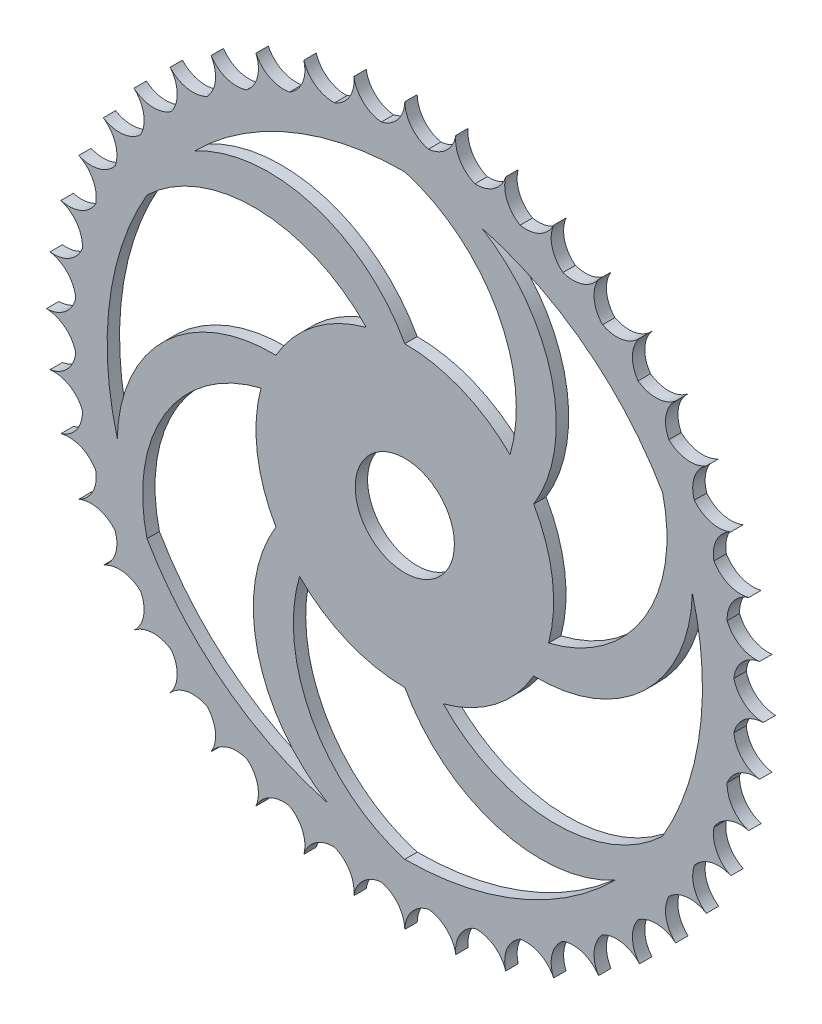
from build123d import *

# Parameters (mm, degrees)
SALIENTE_EXTRUIR1_DEPTH = 1.5875
CROQUIS3_R              = 12.7
CORTAR_EXTRUIR1_DEPTH   = 130.790821914


with BuildPart() as part:
    # Croquis2 → Saliente-Extruir1 (new, symmetric)
    with BuildSketch(Plane.XY):
        with BuildLine():
            ThreePointArc((84.239816471, -6.024948705), (86.969836616, -1.73589321), (91.748505392, 1.878e-06))
            ThreePointArc((91.748505392, 1.878e-06), (86.969836616, 1.735896967), (84.239816471, 6.024952462))
            ThreePointArc((84.239816471, 6.024952462), (86.331652708, 10.658873931), (90.814637898, 13.057175585))
            ThreePointArc((90.814637898, 13.057175585), (85.837565451, 14.095326291), (82.524936735, 17.952203009))
            ThreePointArc((82.524936735, 17.952203009), (83.936005311, 22.836657176), (88.032046263, 25.848542889))
            ThreePointArc((88.032046263, 25.848542889), (82.957888988, 26.167815457), (79.130087269, 29.513998512))
            ThreePointArc((79.130087269, 29.513998512), (79.831662898, 34.549551974), (83.457376031, 38.113708439))
            ThreePointArc((83.457376031, 38.113708439), (78.389429136, 37.7076034), (74.124377419, 40.474974154))
            ThreePointArc((74.124377419, 40.474974154), (74.102178043, 45.559117564), (77.183754293, 49.602988834))
            ThreePointArc((77.183754293, 49.602988834), (72.225186563, 48.479773316), (67.609709002, 50.611996081))
            ThreePointArc((67.609709002, 50.611996081), (66.864186536, 55.641230941), (69.338893898, 60.082495458))
            ThreePointArc((69.338893898, 60.082495458), (64.590647472, 58.26503489), (59.71870188, 59.718703759))
            ThreePointArc((59.71870188, 59.718703759), (58.265033012, 64.590649351), (60.082493579, 69.338895776))
            ThreePointArc((60.082493579, 69.338895776), (55.641229063, 66.864188414), (50.611994202, 67.609710881))
            ThreePointArc((50.611994202, 67.609710881), (48.479771438, 72.225188442), (49.602986956, 77.183756171))
            ThreePointArc((49.602986956, 77.183756171), (45.559115686, 74.102179921), (40.474972276, 74.124379298))
            ThreePointArc((40.474972276, 74.124379298), (37.707601522, 78.389431014), (38.11370656, 83.457377909))
            ThreePointArc((38.11370656, 83.457377909), (34.549550095, 79.831664776), (29.513996633, 79.130089148))
            ThreePointArc((29.513996633, 79.130089148), (26.167813579, 82.957890866), (25.84854101, 88.032048142))
            ThreePointArc((25.84854101, 88.032048142), (22.836655297, 83.93600719), (17.952201131, 82.524938613))
            ThreePointArc((17.952201131, 82.524938613), (14.095324412, 85.837567329), (13.057173707, 90.814639776))
            ThreePointArc((13.057173707, 90.814639776), (10.658872053, 86.331654587), (6.024950583, 84.239818349))
            ThreePointArc((6.024950583, 84.239818349), (1.735895089, 86.969838494), (0, 91.74850727))
            ThreePointArc((0, 91.74850727), (-1.735895089, 86.969838494), (-6.024950583, 84.239818349))
            ThreePointArc((-6.024950583, 84.239818349), (-10.658872053, 86.331654587), (-13.057173707, 90.814639776))
            ThreePointArc((-13.057173707, 90.814639776), (-14.095324412, 85.837567329), (-17.952201131, 82.524938613))
            ThreePointArc((-17.952201131, 82.524938613), (-22.836655297, 83.93600719), (-25.84854101, 88.032048142))
            ThreePointArc((-25.84854101, 88.032048142), (-26.167813579, 82.957890866), (-29.513996633, 79.130089148))
            ThreePointArc((-29.513996633, 79.130089148), (-34.549550095, 79.831664776), (-38.11370656, 83.457377909))
            ThreePointArc((-38.11370656, 83.457377909), (-37.707601522, 78.389431014), (-40.474972276, 74.124379298))
            ThreePointArc((-40.474972276, 74.124379298), (-45.559115686, 74.102179921), (-49.602986956, 77.183756171))
            ThreePointArc((-49.602986956, 77.183756171), (-48.479771438, 72.225188442), (-50.611994202, 67.609710881))
            ThreePointArc((-50.611994202, 67.609710881), (-55.641229063, 66.864188414), (-60.082493579, 69.338895776))
            ThreePointArc((-60.082493579, 69.338895776), (-58.265033012, 64.590649351), (-59.71870188, 59.718703759))
            ThreePointArc((-59.71870188, 59.718703759), (-64.590647472, 58.26503489), (-69.338893898, 60.082495458))
            ThreePointArc((-69.338893898, 60.082495458), (-66.864186536, 55.641230941), (-67.609709002, 50.611996081))
            ThreePointArc((-67.609709002, 50.611996081), (-72.225186563, 48.479773316), (-77.183754293, 49.602988834))
            ThreePointArc((-77.183754293, 49.602988834), (-74.102178043, 45.559117564), (-74.124377419, 40.474974154))
            ThreePointArc((-74.124377419, 40.474974154), (-78.389429136, 37.7076034), (-83.457376031, 38.113708439))
            ThreePointArc((-83.457376031, 38.113708439), (-79.831662898, 34.549551974), (-79.130087269, 29.513998512))
            ThreePointArc((-79.130087269, 29.513998512), (-82.957888988, 26.167815457), (-88.032046263, 25.848542889))
            ThreePointArc((-88.032046263, 25.848542889), (-83.936005311, 22.836657176), (-82.524936735, 17.952203009))
            ThreePointArc((-82.524936735, 17.952203009), (-85.837565451, 14.095326291), (-90.814637898, 13.057175585))
            ThreePointArc((-90.814637898, 13.057175585), (-86.331652708, 10.658873931), (-84.239816471, 6.024952462))
            ThreePointArc((-84.239816471, 6.024952462), (-86.969836616, 1.735896967), (-91.748505392, 1.878e-06))
            ThreePointArc((-91.748505392, 1.878e-06), (-86.969836616, -1.73589321), (-84.239816471, -6.024948705))
            ThreePointArc((-84.239816471, -6.024948705), (-86.331652708, -10.658870175), (-90.814637898, -13.057171828))
            ThreePointArc((-90.814637898, -13.057171828), (-85.837565451, -14.095322534), (-82.524936735, -17.952199253))
            ThreePointArc((-82.524936735, -17.952199253), (-83.936005311, -22.836653419), (-88.032046263, -25.848539132))
            ThreePointArc((-88.032046263, -25.848539132), (-82.957888988, -26.1678117), (-79.130087269, -29.513994755))
            ThreePointArc((-79.130087269, -29.513994755), (-79.831662898, -34.549548217), (-83.457376031, -38.113704682))
            ThreePointArc((-83.457376031, -38.113704682), (-78.389429136, -37.707599644), (-74.124377419, -40.474970397))
            ThreePointArc((-74.124377419, -40.474970397), (-74.102178043, -45.559113808), (-77.183754293, -49.602985077))
            ThreePointArc((-77.183754293, -49.602985077), (-72.225186563, -48.47976956), (-67.609709002, -50.611992324))
            ThreePointArc((-67.609709002, -50.611992324), (-66.864186536, -55.641227185), (-69.338893898, -60.082491701))
            ThreePointArc((-69.338893898, -60.082491701), (-64.590647472, -58.265031134), (-59.71870188, -59.718700002))
            ThreePointArc((-59.71870188, -59.718700002), (-58.265033012, -64.590645594), (-60.082493579, -69.338892019))
            ThreePointArc((-60.082493579, -69.338892019), (-55.641229063, -66.864184658), (-50.611994202, -67.609707124))
            ThreePointArc((-50.611994202, -67.609707124), (-48.479771438, -72.225184685), (-49.602986956, -77.183752415))
            ThreePointArc((-49.602986956, -77.183752415), (-45.559115686, -74.102176164), (-40.474972276, -74.124375541))
            ThreePointArc((-40.474972276, -74.124375541), (-37.707601522, -78.389427257), (-38.11370656, -83.457374152))
            ThreePointArc((-38.11370656, -83.457374152), (-34.549550095, -79.831661019), (-29.513996633, -79.130085391))
            ThreePointArc((-29.513996633, -79.130085391), (-26.167813579, -82.957887109), (-25.84854101, -88.032044385))
            ThreePointArc((-25.84854101, -88.032044385), (-22.836655297, -83.936003433), (-17.952201131, -82.524934856))
            ThreePointArc((-17.952201131, -82.524934856), (-14.095324412, -85.837563572), (-13.057173707, -90.814636019))
            ThreePointArc((-13.057173707, -90.814636019), (-10.658872053, -86.33165083), (-6.024950583, -84.239814592))
            ThreePointArc((-6.024950583, -84.239814592), (-1.735895089, -86.969834738), (0, -91.748503514))
            ThreePointArc((0, -91.748503514), (1.735895089, -86.969834738), (6.024950583, -84.239814592))
            ThreePointArc((6.024950583, -84.239814592), (10.658872053, -86.33165083), (13.057173707, -90.814636019))
            ThreePointArc((13.057173707, -90.814636019), (14.095324412, -85.837563572), (17.952201131, -82.524934856))
            ThreePointArc((17.952201131, -82.524934856), (22.836655297, -83.936003433), (25.84854101, -88.032044385))
            ThreePointArc((25.84854101, -88.032044385), (26.167813579, -82.957887109), (29.513996633, -79.130085391))
            ThreePointArc((29.513996633, -79.130085391), (34.549550095, -79.831661019), (38.11370656, -83.457374152))
            ThreePointArc((38.11370656, -83.457374152), (37.707601522, -78.389427257), (40.474972276, -74.124375541))
            ThreePointArc((40.474972276, -74.124375541), (45.559115686, -74.102176164), (49.602986956, -77.183752415))
            ThreePointArc((49.602986956, -77.183752415), (48.479771438, -72.225184685), (50.611994202, -67.609707124))
            ThreePointArc((50.611994202, -67.609707124), (55.641229063, -66.864184658), (60.082493579, -69.338892019))
            ThreePointArc((60.082493579, -69.338892019), (58.265033012, -64.590645594), (59.71870188, -59.718700002))
            ThreePointArc((59.71870188, -59.718700002), (64.590647472, -58.265031134), (69.338893898, -60.082491701))
            ThreePointArc((69.338893898, -60.082491701), (66.864186536, -55.641227185), (67.609709002, -50.611992324))
            ThreePointArc((67.609709002, -50.611992324), (72.225186563, -48.47976956), (77.183754293, -49.602985077))
            ThreePointArc((77.183754293, -49.602985077), (74.102178043, -45.559113808), (74.124377419, -40.474970397))
            ThreePointArc((74.124377419, -40.474970397), (78.389429136, -37.707599644), (83.457376031, -38.113704682))
            ThreePointArc((83.457376031, -38.113704682), (79.831662898, -34.549548217), (79.130087269, -29.513994755))
            ThreePointArc((79.130087269, -29.513994755), (82.957888988, -26.1678117), (88.032046263, -25.848539132))
            ThreePointArc((88.032046263, -25.848539132), (83.936005311, -22.836653419), (82.524936735, -17.952199253))
            ThreePointArc((82.524936735, -17.952199253), (85.837565451, -14.095322534), (90.814637898, -13.057171828))
            ThreePointArc((90.814637898, -13.057171828), (86.331652708, -10.658870175), (84.239816471, -6.024948705))
        make_face()
    extrude(amount=SALIENTE_EXTRUIR1_DEPTH, both=True)

    # Croquis3 → Cortar-Extruir1 (cut, through all)
    with BuildSketch(Plane.XY.offset(1.5875)):
        Circle(CROQUIS3_R)
        with BuildLine():
            ThreePointArc((0, 76.2), (-29.160477546, 70.399620377), (-53.881536726, 53.881536726))
            ThreePointArc((-53.881536726, 53.881536726), (-23.67230509, 57.15), (0, 38.1))
            ThreePointArc((0, 38.1), (14.580238773, 35.199810189), (26.940768363, 26.940768363))
            ThreePointArc((26.940768363, 26.940768363), (23.67230509, 57.15), (0, 76.2))
        make_face()
        with BuildLine():
            ThreePointArc((65.991135768, 38.1), (46.38762089, 60.45352453), (19.722011237, 73.603547963))
            ThreePointArc((19.722011237, 73.603547963), (37.657199281, 49.075817574), (32.995567884, 19.05))
            ThreePointArc((32.995567884, 19.05), (37.774049218, 4.973047924), (36.801773982, -9.861005618))
            ThreePointArc((36.801773982, -9.861005618), (61.329504371, 8.074182426), (65.991135768, 38.1))
        make_face()
        with BuildLine():
            ThreePointArc((65.991135768, -38.1), (75.548098437, -9.946095847), (73.603547963, 19.722011237))
            ThreePointArc((73.603547963, 19.722011237), (61.329504371, -8.074182426), (32.995567884, -19.05))
            ThreePointArc((32.995567884, -19.05), (23.193810445, -30.226762265), (9.861005618, -36.801773982))
            ThreePointArc((9.861005618, -36.801773982), (37.657199281, -49.075817574), (65.991135768, -38.1))
        make_face()
        with BuildLine():
            ThreePointArc((0, -76.2), (29.160477546, -70.399620377), (53.881536726, -53.881536726))
            ThreePointArc((53.881536726, -53.881536726), (23.67230509, -57.15), (0, -38.1))
            ThreePointArc((0, -38.1), (-14.580238773, -35.199810189), (-26.940768363, -26.940768363))
            ThreePointArc((-26.940768363, -26.940768363), (-23.67230509, -57.15), (0, -76.2))
        make_face()
        with BuildLine():
            ThreePointArc((-65.991135768, -38.1), (-46.38762089, -60.45352453), (-19.722011237, -73.603547963))
            ThreePointArc((-19.722011237, -73.603547963), (-37.657199281, -49.075817574), (-32.995567884, -19.05))
            ThreePointArc((-32.995567884, -19.05), (-37.774049218, -4.973047924), (-36.801773982, 9.861005618))
            ThreePointArc((-36.801773982, 9.861005618), (-61.329504371, -8.074182426), (-65.991135768, -38.1))
        make_face()
        with BuildLine():
            ThreePointArc((-65.991135768, 38.1), (-75.548098437, 9.946095847), (-73.603547963, -19.722011237))
            ThreePointArc((-73.603547963, -19.722011237), (-61.329504371, 8.074182426), (-32.995567884, 19.05))
            ThreePointArc((-32.995567884, 19.05), (-23.193810445, 30.226762265), (-9.861005618, 36.801773982))
            ThreePointArc((-9.861005618, 36.801773982), (-37.657199281, 49.075817574), (-65.991135768, 38.1))
        make_face()
    extrude(amount=-CORTAR_EXTRUIR1_DEPTH, mode=Mode.SUBTRACT)


solid = part.part
